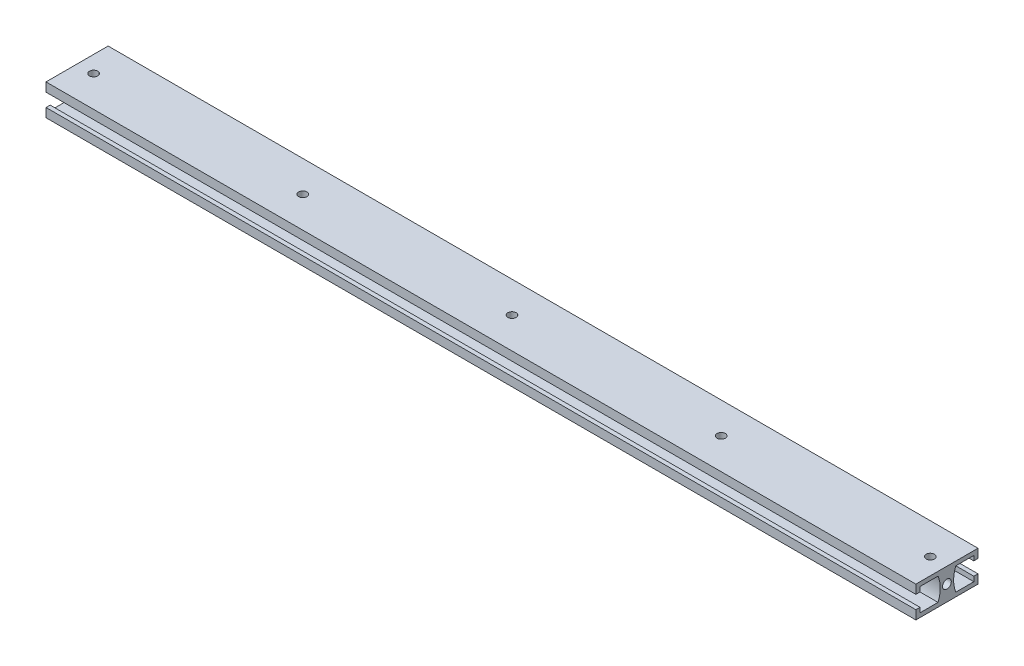
from build123d import *

# Parameters (mm, degrees)
SKETCH1_W                   = 420
SKETCH1_H                   = 30
SKETCH1_R                   = 2
BOSS_EXTRUDE1_DEPTH         = 15
SKETCH2_W                   = 2
SKETCH2_H                   = 6.4
CUT_EXTRUDE1_DEPTH          = 421
TAP_DRILL_FOR_M5X0_8_TAP1_D = 4.2


with BuildPart() as part:
    # Sketch1 → Boss-Extrude1 (new body)
    with BuildSketch(Plane(origin=(0, 0, 0), x_dir=(1, 0, 0), z_dir=(0, 1, 0))):
        Rectangle(SKETCH1_W, SKETCH1_H)
        Circle(SKETCH1_R, mode=Mode.SUBTRACT)
        with Locations((-101, 0)):
            Circle(SKETCH1_R, mode=Mode.SUBTRACT)
        with Locations((-202, 0)):
            Circle(SKETCH1_R, mode=Mode.SUBTRACT)
        with Locations((101, 0)):
            Circle(SKETCH1_R, mode=Mode.SUBTRACT)
        with Locations((202, 0)):
            Circle(SKETCH1_R, mode=Mode.SUBTRACT)
    extrude(amount=BOSS_EXTRUDE1_DEPTH)

    # Sketch2 → Cut-Extrude1 (cut, through all)
    with BuildSketch(Plane(origin=(210, 0, 0), x_dir=(0, 0, -1), z_dir=(1, 0, 0))):
        with BuildLine():
            Line((13, 4.3), (13, 10.7))
            Line((13, 10.7), (13, 13))
            Line((13, 13), (4.284945547, 13))
            ThreePointArc((4.284945547, 13), (3.23845307, 7.5), (4.284945547, 2))
            Line((4.284945547, 2), (13, 2))
            Line((13, 2), (13, 4.3))
        make_face()
        with Locations((14, 7.5)):
            Rectangle(SKETCH2_W, SKETCH2_H)
        with BuildLine():
            ThreePointArc((-4.284945547, 2), (-3.23845307, 7.5), (-4.284945547, 13))
            Line((-4.284945547, 13), (-13, 13))
            Line((-13, 13), (-13, 10.7))
            Line((-13, 10.7), (-13, 4.3))
            Line((-13, 4.3), (-13, 2))
            Line((-13, 2), (-4.284945547, 2))
        make_face()
        with Locations((-14, 7.5)):
            Rectangle(SKETCH2_W, SKETCH2_H)
    extrude(amount=-CUT_EXTRUDE1_DEPTH, mode=Mode.SUBTRACT)

    # Tap Drill for M5x0.8 Tap1 (through all)
    with Locations(Plane(origin=(210, 0, 0), x_dir=(0, 0, -1), z_dir=(1, 0, 0))):
        with Locations((0, 7.499198906)):
            Hole(TAP_DRILL_FOR_M5X0_8_TAP1_D / 2)


solid = part.part
